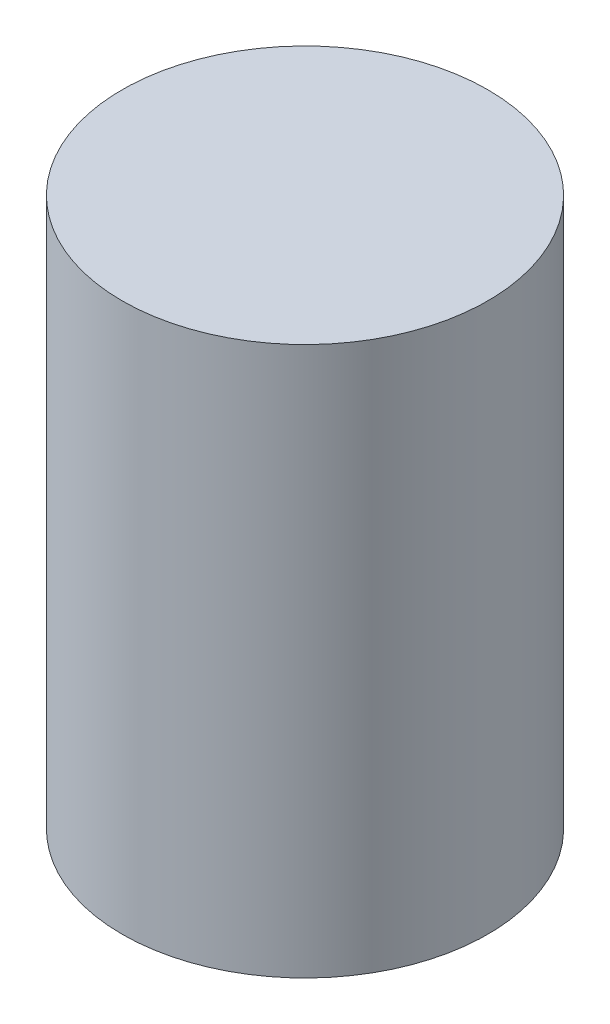
from build123d import *

# Parameters (mm, degrees)
SKETCH1_R           = 1.524
BOSS_EXTRUDE1_DEPTH = 4.572


with BuildPart() as part:
    # Sketch1 → Boss-Extrude1 (new body)
    with BuildSketch(Plane(origin=(0, 0, 0), x_dir=(1, 0, 0), z_dir=(0, 1, 0))):
        Circle(SKETCH1_R)
    extrude(amount=BOSS_EXTRUDE1_DEPTH)


solid = part.part
